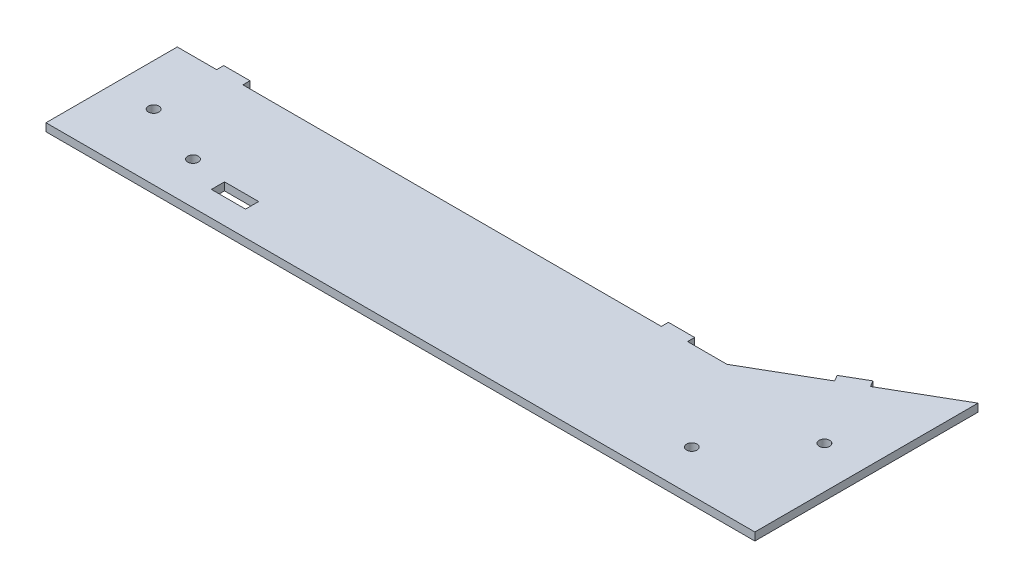
from build123d import *

# Parameters (mm, degrees)
BOSS_EXTRUDE1_DEPTH = 3
CUT_EXTRUDE1_REACH  = 5
SKETCH2_R           = 2
CUT_EXTRUDE2_REACH  = 5
SKETCH3_R           = 2
SKETCH4_W           = 10
SKETCH4_H           = 3
BOSS_EXTRUDE3_DEPTH = 2.7
SKETCH5_W           = 10
SKETCH5_H           = 3
BOSS_EXTRUDE4_DEPTH = 2.7
CUT_EXTRUDE3_REACH  = 5
SKETCH6_W           = 13
SKETCH6_H           = 5


with BuildPart() as part:
    # Sketch1 → Boss-Extrude1 (new body)
    with BuildSketch(Plane(origin=(0, 0, 0), x_dir=(1, 0, 0), z_dir=(0, 1, 0))):
        Polygon((101.124303582, 11.213732055), (101.124303582, 66.273277114), (40.502525317, 31.273277114), (-168.875696418, 31.273277114), (-168.875696418, -18.726722886), (101.124303582, -18.726722886), align=None)
    extrude(amount=BOSS_EXTRUDE1_DEPTH)

    # Sketch2 → Cut-Extrude1 (cut, up to next)
    with BuildSketch(Plane(origin=(0, 3, 0), x_dir=(1, 0, 0), z_dir=(0, 1, 0)), mode=Mode.PRIVATE) as cut_extrude1_sk1:
        with Locations(Location((-152.875696418, 6.273277114, 0), (0, 0, 270))):  # turned: the seam where the file's is
            Circle(SKETCH2_R)
    cut_extrude1_tool1 = extrude(cut_extrude1_sk1.sketch, amount=-CUT_EXTRUDE1_REACH, mode=Mode.PRIVATE) & part.part
    add(cut_extrude1_tool1.solids().sort_by_distance((-152.875696, 3, -6.273277))[0], mode=Mode.SUBTRACT)
    # Sketch2 → Cut-Extrude1 (cut, up to next)
    with BuildSketch(Plane(origin=(0, 3, 0), x_dir=(1, 0, 0), z_dir=(0, 1, 0)), mode=Mode.PRIVATE) as cut_extrude1_sk2:
        with Locations(Location((85.124303582, 23.773277114, 0), (0, 0, 270))):  # turned: the seam where the file's is
            Circle(SKETCH2_R)
    cut_extrude1_tool2 = extrude(cut_extrude1_sk2.sketch, amount=-CUT_EXTRUDE1_REACH, mode=Mode.PRIVATE) & part.part
    add(cut_extrude1_tool2.solids().sort_by_distance((85.124304, 3, -23.773277))[0], mode=Mode.SUBTRACT)

    # Sketch3 → Cut-Extrude2 (cut, up to next)
    with BuildSketch(Plane(origin=(0, 3, 0), x_dir=(1, 0, 0), z_dir=(0, 1, 0)), mode=Mode.PRIVATE) as cut_extrude2_sk1:
        with Locations(Location((-128.875696418, -2.726722886, 0), (0, 0, 270))):  # turned: the seam where the file's is
            Circle(SKETCH3_R)
    cut_extrude2_tool1 = extrude(cut_extrude2_sk1.sketch, amount=-CUT_EXTRUDE2_REACH, mode=Mode.PRIVATE) & part.part
    add(cut_extrude2_tool1.solids().sort_by_distance((-128.875696, 3, 2.726723))[0], mode=Mode.SUBTRACT)
    # Sketch3 → Cut-Extrude2 (cut, up to next)
    with BuildSketch(Plane(origin=(0, 3, 0), x_dir=(1, 0, 0), z_dir=(0, 1, 0)), mode=Mode.PRIVATE) as cut_extrude2_sk2:
        with Locations(Location((61.124303582, -2.726722886, 0), (0, 0, 270))):  # turned: the seam where the file's is
            Circle(SKETCH3_R)
    cut_extrude2_tool2 = extrude(cut_extrude2_sk2.sketch, amount=-CUT_EXTRUDE2_REACH, mode=Mode.PRIVATE) & part.part
    add(cut_extrude2_tool2.solids().sort_by_distance((61.124304, 3, 2.726723))[0], mode=Mode.SUBTRACT)

    # Sketch4 → Boss-Extrude3 (add)
    with BuildSketch(Plane.XY.offset(-31.273277114)):
        with Locations((-148.875696418, 1.5)):
            Rectangle(SKETCH4_W, SKETCH4_H)
        with Locations((20.502525317, 1.5)):
            Rectangle(SKETCH4_W, SKETCH4_H)
    extrude(amount=-BOSS_EXTRUDE3_DEPTH)

    # Sketch5 → Boss-Extrude4 (add)
    with BuildSketch(Plane(origin=(-3.416094891, 0, -5.916849915), x_dir=(-0.866025404, 0, 0.5), z_dir=(-0.5, 0, -0.866025404))):
        with Locations((-85.712854399, 1.5)):
            Rectangle(SKETCH5_W, SKETCH5_H)
    extrude(amount=BOSS_EXTRUDE4_DEPTH)

    # Sketch6 → Cut-Extrude3 (cut, up to next)
    with BuildSketch(Plane(origin=(0, 3, 0), x_dir=(1, 0, 0), z_dir=(0, 1, 0)), mode=Mode.PRIVATE) as cut_extrude3_sk1:
        with Locations((-108.875696418, -6.726722886)):
            Rectangle(SKETCH6_W, SKETCH6_H)
    cut_extrude3_tool1 = extrude(cut_extrude3_sk1.sketch, amount=-CUT_EXTRUDE3_REACH, mode=Mode.PRIVATE) & part.part
    add(cut_extrude3_tool1.solids().sort_by_distance((-108.875696, 3, 6.726723))[0], mode=Mode.SUBTRACT)


solid = part.part
